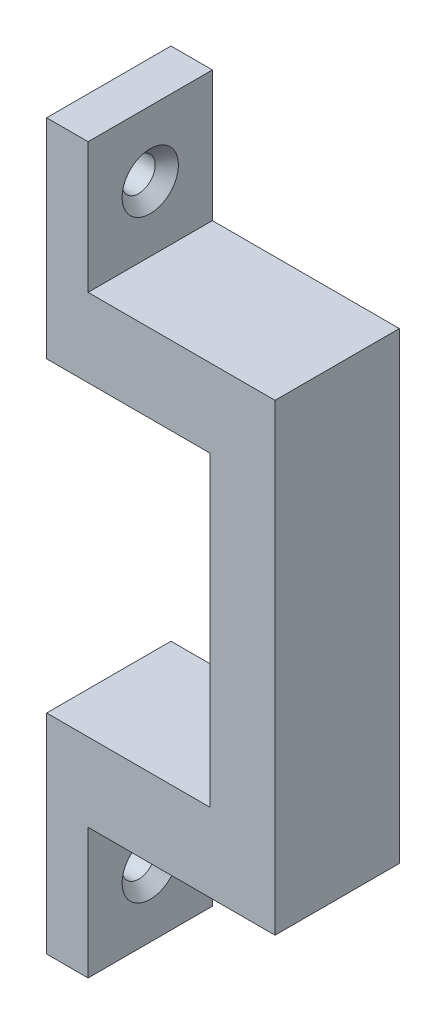
from build123d import *

# Parameters (mm, degrees)
BOSS_EXTRUDE1_DEPTH             = 9.525
F_2_CLEARANCE_HOLE1_D           = 2.032
F_2_CLEARANCE_HOLE1_DEPTH       = 6.35
F_2_CLEARANCE_HOLE1_TIP         = 0.610474389
F_3_CLEARANCE_HOLE2_D           = 2.54
F_3_CLEARANCE_HOLE2_CSINK_D     = 4.318
F_3_CLEARANCE_HOLE2_CSINK_ANGLE = 90


with BuildPart() as part:
    # Sketch1 → Boss-Extrude1 (new body)
    with BuildSketch(Plane.XY):
        Polygon((0, 11.75), (0, -11.75), (-12.5, -11.75), (-12.5, -27.75), (-9.325, -27.75), (-9.325, -17.75), (5, -17.75), (5, 17.75), (-9.325, 17.75), (-9.325, 27.75), (-12.5, 27.75), (-12.5, 11.75), align=None)
    extrude(amount=BOSS_EXTRUDE1_DEPTH)

    # #2 Clearance Hole1
    with Locations(Plane(origin=(0, 0, 0), x_dir=(-1, 0, 0), z_dir=(0, 0, -1))):
        with Locations((6.25, 14), (6.25, -14)):
            Hole(F_2_CLEARANCE_HOLE1_D / 2, depth=F_2_CLEARANCE_HOLE1_DEPTH)
            with Locations((0, 0, -(F_2_CLEARANCE_HOLE1_DEPTH + F_2_CLEARANCE_HOLE1_TIP / 2))):  # 118° drill point
                Cone(0, F_2_CLEARANCE_HOLE1_D / 2, F_2_CLEARANCE_HOLE1_TIP, mode=Mode.SUBTRACT)

    # #3 Clearance Hole2 (through all)
    with Locations(Plane(origin=(-9.325, 0, 0), x_dir=(0, 0, -1), z_dir=(1, 0, 0))):
        with Locations((-4.7625, 22.75), (-4.7625, -22.75)):
            CounterSinkHole(F_3_CLEARANCE_HOLE2_D / 2, F_3_CLEARANCE_HOLE2_CSINK_D / 2, counter_sink_angle=F_3_CLEARANCE_HOLE2_CSINK_ANGLE)


solid = part.part
